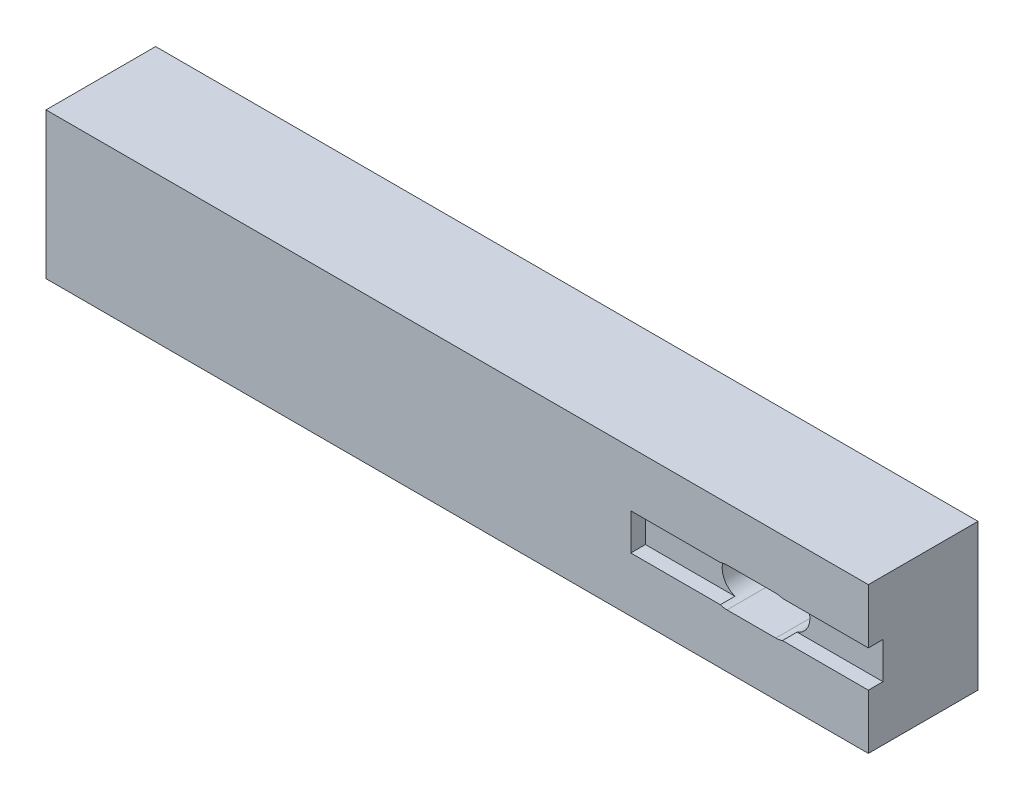
from build123d import *

# Parameters (mm, degrees)
SKETCH1_W           = 24.634
SKETCH1_H           = 13
BOSS_EXTRUDE1_DEPTH = 10
SKETCH4_W           = 82.5
SKETCH4_H           = 13
BOSS_EXTRUDE4_DEPTH = 15
SKETCH5_W           = 28
SKETCH5_H           = 3.5
BOSS_EXTRUDE5_DEPTH = 15
CUT_EXTRUDE1_DEPTH  = 26
SKETCH7_W           = 32.5
SKETCH7_H           = 5
CUT_EXTRUDE2_DEPTH  = 2
SKETCH8_W           = 10
SKETCH8_H           = 13
CUT_EXTRUDE3_DEPTH  = 25.634
SKETCH9_W           = 15
SKETCH9_H           = 3.5
BOSS_EXTRUDE6_DEPTH = 54.5
SKETCH10_W          = 15
SKETCH10_H          = 20
BOSS_EXTRUDE7_DEPTH = 30


with BuildPart() as part:
    # Sketch1 → Boss-Extrude1 (new body)
    with BuildSketch(Plane.XY):
        with Locations((12.317, 6.5)):
            Rectangle(SKETCH1_W, SKETCH1_H)
    extrude(amount=BOSS_EXTRUDE1_DEPTH)

    # Sketch4 → Boss-Extrude4 (add)
    with BuildSketch(Plane.XY.offset(10)):
        with Locations((41.25, 6.5)):
            Rectangle(SKETCH4_W, SKETCH4_H)
    extrude(amount=BOSS_EXTRUDE4_DEPTH)

    # Sketch5 → Boss-Extrude5 (add)
    with BuildSketch(Plane.XY.offset(25)):
        with Locations((68.5, -1.75)):
            Rectangle(SKETCH5_W, SKETCH5_H)
        with Locations((68.5, 14.75)):
            Rectangle(SKETCH5_W, SKETCH5_H)
    extrude(amount=-BOSS_EXTRUDE5_DEPTH)

    # Sketch6 → Cut-Extrude1 (cut, through all)
    with BuildSketch(Plane.XY.offset(25)):
        with BuildLine():
            Line((63.16, 9.16), (69.84, 9.16))
            ThreePointArc((69.84, 9.16), (72.5, 6.5), (69.84, 3.84))
            Line((69.84, 3.84), (63.16, 3.84))
            ThreePointArc((63.16, 3.84), (60.5, 6.5), (63.16, 9.16))
        make_face()
    extrude(amount=-CUT_EXTRUDE1_DEPTH, mode=Mode.SUBTRACT)

    # Sketch7 → Cut-Extrude2 (cut)
    with BuildSketch(Plane.XY.offset(25)):
        with Locations((66.25, 6.5)):
            Rectangle(SKETCH7_W, SKETCH7_H)
    extrude(amount=-CUT_EXTRUDE2_DEPTH, mode=Mode.SUBTRACT)

    # Sketch8 → Cut-Extrude3 (cut, through all)
    with BuildSketch(Plane(origin=(24.634, 0, 0), x_dir=(0, 0, -1), z_dir=(1, 0, 0))):
        with Locations((-5, 6.5)):
            Rectangle(SKETCH8_W, SKETCH8_H)
    extrude(amount=-CUT_EXTRUDE3_DEPTH, mode=Mode.SUBTRACT)

    # Sketch9 → Boss-Extrude6 (add)
    with BuildSketch(Plane.ZY.offset(-54.5)):
        with Locations((17.5, 14.75)):
            Rectangle(SKETCH9_W, SKETCH9_H)
        with Locations((17.5, -1.75)):
            Rectangle(SKETCH9_W, SKETCH9_H)
    extrude(amount=BOSS_EXTRUDE6_DEPTH)

    # Sketch10 → Boss-Extrude7 (add)
    with BuildSketch(Plane.ZY):
        with Locations((17.5, 6.5)):
            Rectangle(SKETCH10_W, SKETCH10_H)
    extrude(amount=BOSS_EXTRUDE7_DEPTH)


solid = part.part
